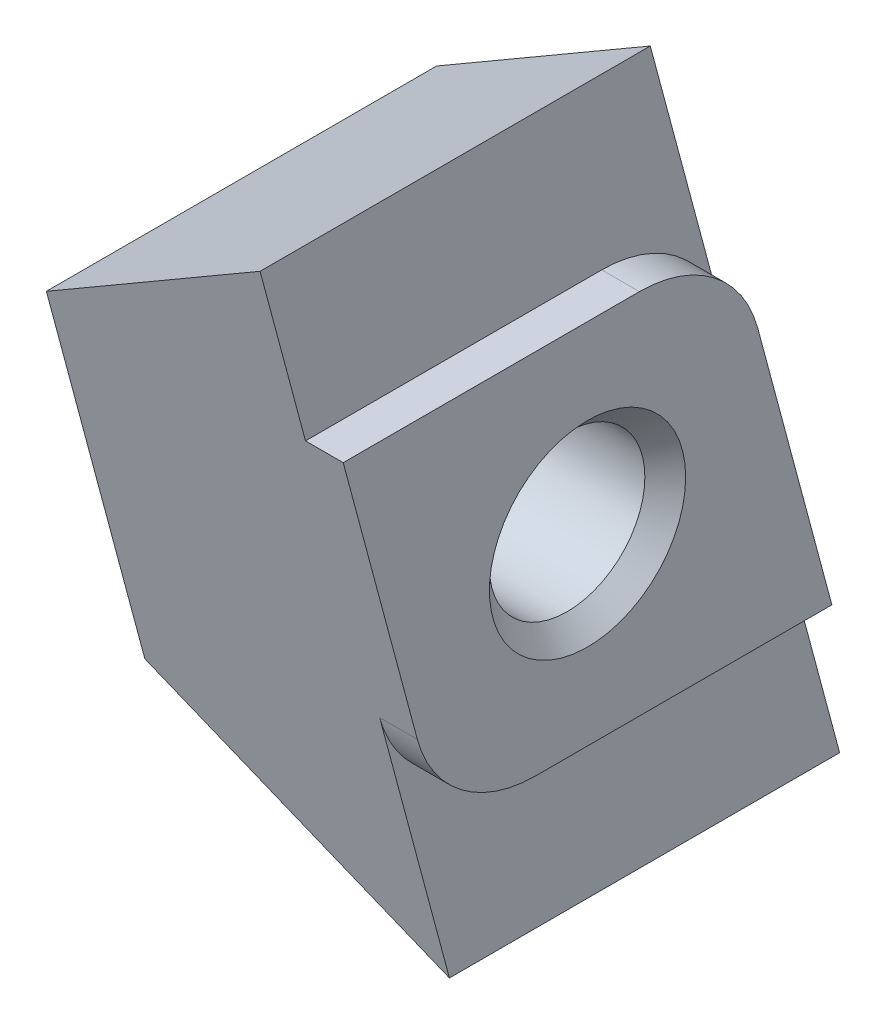
from build123d import *

# Parameters (mm, degrees)
EXTRUDE1_DEPTH        = 0.8
EXTRUDE2_DEPTH        = 5.5
DRAFT1_ANGLE          = -33.206570315
DRAFT2_ANGLE          = -33.206570315
M4_TAPPED_HOLE1_D     = 3.3
M4_TAPPED_HOLE1_DEPTH = 6.3
CHAMFER1_SIZE         = 0.433


with BuildPart() as part:
    # Sketch1 → Extrude1 (new body)
    with BuildSketch(Plane(origin=(0, 0, 0), x_dir=(0, 0, -1), z_dir=(1, 0, 0))):
        with BuildLine():
            Line((1.101052702, 3.9), (-5.186106572, 3.9))
            Line((-5.186106572, 3.9), (-3.612459851, -1.972929517))
            ThreePointArc((-3.612459851, -1.972929517), (-2.683832418, -3.362718685), (-1.101052702, -3.9))
            Line((-1.101052702, -3.9), (5.186106572, -3.9))
            Line((5.186106572, -3.9), (3.612459851, 1.972929517))
            ThreePointArc((3.612459851, 1.972929517), (2.683832418, 3.362718685), (1.101052702, 3.9))
        make_face()
    extrude(amount=-EXTRUDE1_DEPTH)

    # Sketch2 → Extrude2 (add)
    with BuildSketch(Plane.ZY.offset(0.8)):
        with BuildLine():
            Line((2.131485778, -7.5), (-6.150723665, -7.5))
            add(Edge.make_bspline(
                [(-2.131485778, 7.5), (-3.471231741, 2.5), (-4.810977703, -2.5), (-6.150723665, -7.5)],
                knots=[0, 0, 0, 0, 1, 1, 1, 1], degree=3))
            Line((-2.131485778, 7.5), (6.150723665, 7.5))
            add(Edge.make_bspline(
                [(2.131485778, -7.5), (3.471231741, -2.5), (4.810977703, 2.5), (6.150723665, 7.5)],
                knots=[0, 0, 0, 0, 1, 1, 1, 1], degree=3))
        make_face()
    extrude(amount=EXTRUDE2_DEPTH)

    # Draft1
    draft1_faces = [part.faces().sort_by_distance(p)[0] for p in [
        (-3.55, 7.5, 2.009618943),
    ]]
    draft(draft1_faces, Plane(origin=(-0.8, 0, 4.141104722), x_dir=(0, 0, 1), z_dir=(1, 0, 0)), DRAFT1_ANGLE)

    # Draft2
    draft2_faces = [part.faces().sort_by_distance(p)[0] for p in [
        (-3.55, -7.5, -2.009618943),
    ]]
    draft(draft2_faces, Plane(origin=(-0.8, 0, 4.141104722), x_dir=(0, 0, 1), z_dir=(1, 0, 0)), DRAFT2_ANGLE)

    # M4 Tapped Hole1
    with Locations(Plane.ZY.offset(6.3)):
        with Locations((0, 0)):
            Hole(M4_TAPPED_HOLE1_D / 2, depth=M4_TAPPED_HOLE1_DEPTH)

    # Chamfer1
    chamfer1_edges = [part.edges().sort_by_distance(p)[0] for p in [
        (-6.3, 0, 1.65),
        (0, 0, 1.65),
    ]]
    chamfer(chamfer1_edges, length=CHAMFER1_SIZE)


solid = part.part
